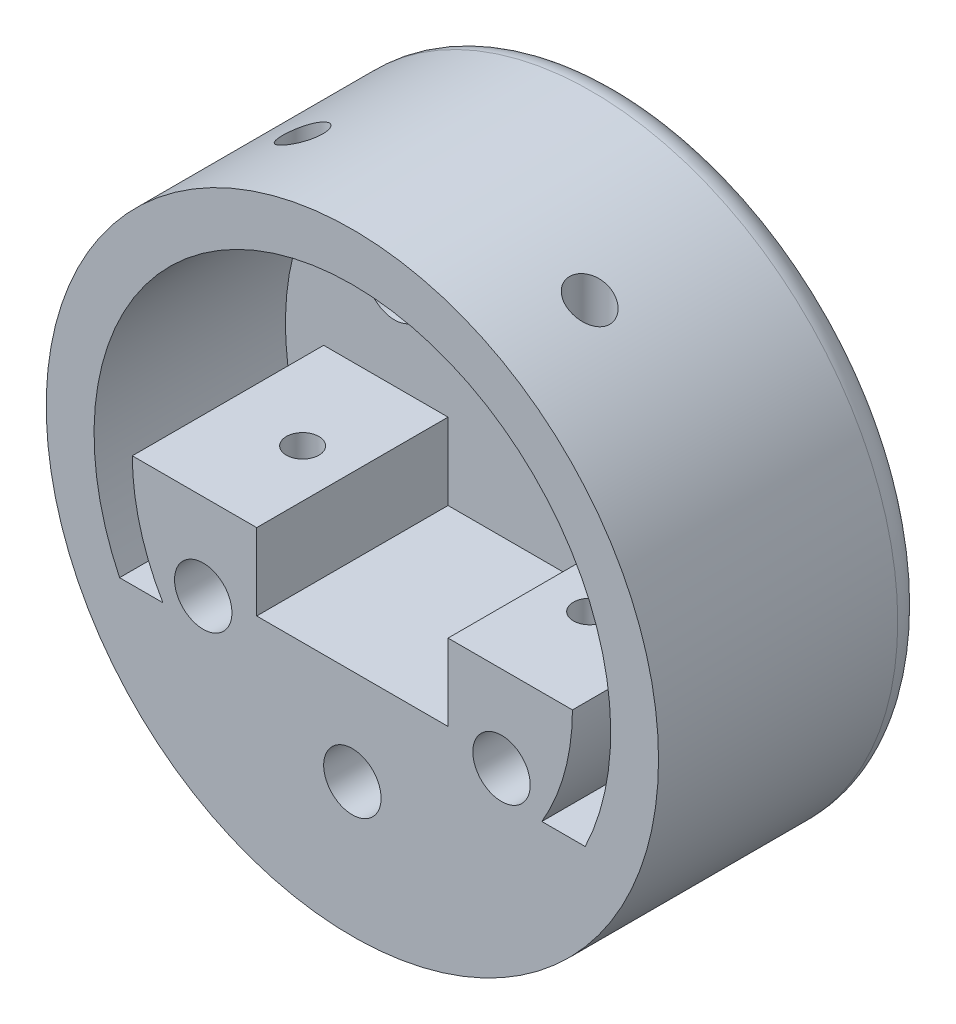
from build123d import *

# Parameters (mm, degrees)
SKETCH_1_R               = 50
EXTRUDE_1_DEPTH          = 42
SKETCH_2_R               = 47.45
CUT_EXTRUDE_1_DEPTH      = 9
SKETCH_3_R               = 43
CUT_EXTRUDE_2_DEPTH      = 5
SKETCH_4_R               = 1.7
CUT_EXTRUDE_3_DEPTH      = 49
SKETCH_5_R               = 50
SKETCH_5_R_2             = 32
SKETCH_5_R_3             = 1.7
CUT_EXTRUDE_4_DEPTH      = 20
FILLET_1_R               = 2
FILLET_2_R               = 2
SKETCH_6_R               = 1.7
CUT_EXTRUDE_5_DEPTH      = 83.24354078
CUT_EXTRUDE_5_DEPTH_BACK = 83.24354078
SKETCH_7_R               = 3
CUT_EXTRUDE_6_DEPTH      = 17.5
SKETCH_8_R               = 3
CUT_EXTRUDE_7_DEPTH      = 8
SKETCH_9_R               = 2.1
CUT_EXTRUDE_8_DEPTH      = 5
SKETCH_10_R              = 3
CUT_EXTRUDE_9_DEPTH      = 2.5
SKETCH_11_R              = 50
SKETCH_11_R_2            = 32
CUT_EXTRUDE_10_DEPTH     = 83.24354078
FILLET_3_R               = 3


with BuildPart() as part:
    # 草图1 → 凸台-拉伸1 (new body)
    with BuildSketch(Plane.XY):
        with Locations(Location((0, 0, 0), (0, 0, 180))):
            Circle(SKETCH_1_R)
    extrude(amount=EXTRUDE_1_DEPTH)

    # 草图2 → 切除-拉伸1 (cut)
    with BuildSketch(Plane(origin=(0, 0, 0), x_dir=(-1, 0, 0), z_dir=(0, 0, -1))):
        Circle(SKETCH_2_R)
    extrude(amount=-CUT_EXTRUDE_1_DEPTH, mode=Mode.SUBTRACT)

    # 草图3 → 切除-拉伸2 (cut)
    with BuildSketch(Plane(origin=(0, 0, 9), x_dir=(-1, 0, 0), z_dir=(0, 0, -1))):
        Circle(SKETCH_3_R)
    extrude(amount=-CUT_EXTRUDE_2_DEPTH, mode=Mode.SUBTRACT)

    # 草图4 → 切除-拉伸3 (cut)
    with BuildSketch(Plane(origin=(0, 0, 14), x_dir=(-1, 0, 0), z_dir=(0, 0, -1))):
        with Locations((0, -18)):
            Circle(SKETCH_4_R)
        with Locations((-15.588457268, -9)):
            Circle(SKETCH_4_R)
        with Locations((-15.588457268, 9)):
            Circle(SKETCH_4_R)
        with Locations((0, 18)):
            Circle(SKETCH_4_R)
        with Locations((15.588457268, 9)):
            Circle(SKETCH_4_R)
        with Locations((15.588457268, -9)):
            Circle(SKETCH_4_R)
    extrude(amount=-CUT_EXTRUDE_3_DEPTH, mode=Mode.SUBTRACT)

    # 草图5 → 切除-拉伸4 (cut)
    with BuildSketch(Plane.XY.offset(42)):
        with Locations(Location((0, 0, 0), (0, 0, 180))):
            Circle(SKETCH_5_R)
        Circle(SKETCH_5_R_2, mode=Mode.SUBTRACT)
        with BuildLine():
            Line((10, 0), (23, 0))
            ThreePointArc((23, 0), (22.18603902, -6.06462469), (19.801767598, -11.7))
            Line((19.801767598, -11.7), (24.333310502, -11.7))
            ThreePointArc((24.333310502, -11.7), (0, 27), (-24.333310502, -11.7))
            Line((-24.333310502, -11.7), (-19.801767598, -11.7))
            ThreePointArc((-19.801767598, -11.7), (-22.18603902, -6.06462469), (-23, 0))
            Line((-23, 0), (-10, 0))
            Line((-10, 0), (-10, -8))
            Line((-10, -8), (10, -8))
            Line((10, -8), (10, 0))
        make_face()
        with Locations(Location((-15.588457268, 9, 0), (0, 0, 180))):
            Circle(SKETCH_5_R_3, mode=Mode.SUBTRACT)
        with Locations(Location((0, 18, 0), (0, 0, 180))):
            Circle(SKETCH_5_R_3, mode=Mode.SUBTRACT)
        with Locations(Location((15.588457268, 9, 0), (0, 0, 180))):
            Circle(SKETCH_5_R_3, mode=Mode.SUBTRACT)
    extrude(amount=-CUT_EXTRUDE_4_DEPTH, mode=Mode.SUBTRACT)

    # 圆角1
    fillet_1_edges = [part.edges().sort_by_distance(p)[0] for p in [
        (50, 0, 22),
    ]]
    fillet(fillet_1_edges, radius=FILLET_1_R)

    # 圆角2
    fillet_2_edges = [part.edges().sort_by_distance(p)[0] for p in [
        (-32, 0, 22),
    ]]
    fillet(fillet_2_edges, radius=FILLET_2_R)

    # 草图6 → 切除-拉伸5 (cut, two sides)
    with BuildSketch(Plane(origin=(0, 0, 0), x_dir=(1, 0, 0), z_dir=(0, 1, 0))) as cut_extrude_5_sk:
        with Locations(Location((-15, -32.2, 0), (0, 0, 270))):
            Circle(SKETCH_6_R)
        with Locations(Location((15, -32.2, 0), (0, 0, 270))):
            Circle(SKETCH_6_R)
    extrude(amount=CUT_EXTRUDE_5_DEPTH, mode=Mode.SUBTRACT)
    extrude(cut_extrude_5_sk.sketch, amount=-CUT_EXTRUDE_5_DEPTH_BACK, mode=Mode.SUBTRACT)

    # 草图7 → 切除-拉伸6 (cut)
    with BuildSketch(Plane.XY.offset(42)):
        with Locations((-15.588457268, -9)):
            Circle(SKETCH_7_R)
        with Locations((0, -18)):
            Circle(SKETCH_7_R)
        with Locations((15.588457268, -9)):
            Circle(SKETCH_7_R)
    extrude(amount=-CUT_EXTRUDE_6_DEPTH, mode=Mode.SUBTRACT)

    # 草图8 → 切除-拉伸7 (cut)
    with BuildSketch(Plane(origin=(0, -23, 0), x_dir=(1, 0, 0), z_dir=(0, 1, 0))):
        with Locations(Location((-15, -32.2, 0), (0, 0, 270))):
            Circle(SKETCH_8_R)
        with Locations(Location((15, -32.2, 0), (0, 0, 270))):
            Circle(SKETCH_8_R)
    extrude(amount=-CUT_EXTRUDE_7_DEPTH, mode=Mode.SUBTRACT)

    # 草图9 → 切除-拉伸8 (cut, symmetric)
    with BuildSketch(Plane(origin=(0, 25, 0), x_dir=(1, 0, 0), z_dir=(0, 1, 0))):
        with Locations(Location((-15, -32.2, 0), (0, 0, 270))):
            Circle(SKETCH_9_R)
        with Locations(Location((15, -32.2, 0), (0, 0, 270))):
            Circle(SKETCH_9_R)
    extrude(amount=CUT_EXTRUDE_8_DEPTH, both=True, mode=Mode.SUBTRACT)

    # 草图10 → 切除-拉伸9 (cut)
    with BuildSketch(Plane.XY.offset(22)):
        with Locations((-15.588457268, 9)):
            Circle(SKETCH_10_R)
        with Locations((0, 18)):
            Circle(SKETCH_10_R)
        with Locations((15.588457268, 9)):
            Circle(SKETCH_10_R)
    extrude(amount=-CUT_EXTRUDE_9_DEPTH, mode=Mode.SUBTRACT)

    # 草图11 → 切除-拉伸10 (cut, through all)
    with BuildSketch(Plane.XY.offset(42)):
        Circle(SKETCH_11_R)
        Circle(SKETCH_11_R_2, mode=Mode.SUBTRACT)
    extrude(amount=-CUT_EXTRUDE_10_DEPTH, mode=Mode.SUBTRACT)

    # 圆角3
    fillet_3_edges = [part.edges().sort_by_distance(p)[0] for p in [
        (-32, 0, 14),
    ]]
    fillet(fillet_3_edges, radius=FILLET_3_R)


solid = part.part
